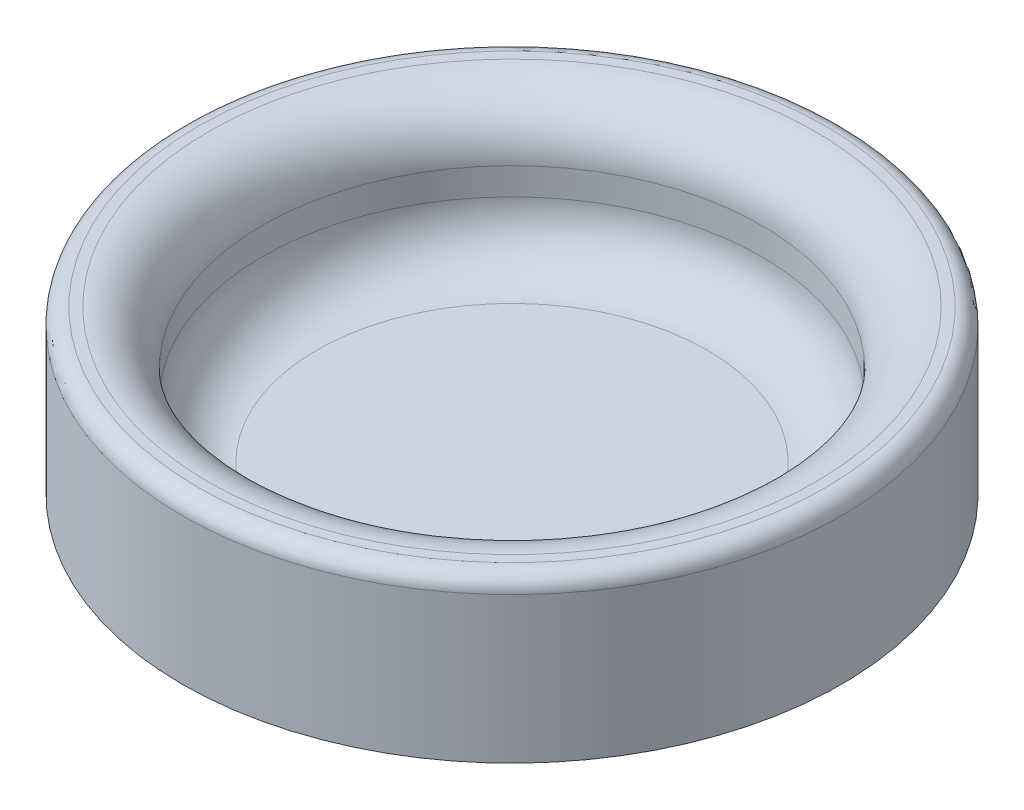
from build123d import *

# Parameters (mm, degrees)
SKETCH1_R           = 60.957989534
BOSS_EXTRUDE1_DEPTH = 5
SKETCH1_4_R         = 60.957989534
SKETCH1_4_R_2       = 46.132101341
BOSS_EXTRUDE2_DEPTH = 30
FILLET2_R           = 10
FILLET3_R           = 10
FILLET5_R           = 3


with BuildPart() as part:
    # Sketch1 → Boss-Extrude1 (new body)
    with BuildSketch(Plane(origin=(0, 0, 0), x_dir=(1, 0, 0), z_dir=(0, 1, 0))):
        with Locations((-18.5585839, 19.037515097)):
            Circle(SKETCH1_R)
    extrude(amount=BOSS_EXTRUDE1_DEPTH)

    # Sketch1_4 → Boss-Extrude2 (add)
    with BuildSketch(Plane(origin=(0, 0, 0), x_dir=(1, 0, 0), z_dir=(0, 1, 0))):
        with Locations((-18.5585839, 19.037515097)):
            Circle(SKETCH1_4_R)
        with Locations((-18.5585839, 19.037515097)):
            Circle(SKETCH1_4_R_2, mode=Mode.SUBTRACT)
    extrude(amount=BOSS_EXTRUDE2_DEPTH)

    # Fillet2
    fillet2_edges = [part.edges().sort_by_distance(p)[0] for p in [
        (-64.69068524, 5, -19.037515097),
    ]]
    fillet(fillet2_edges, radius=FILLET2_R)

    # Fillet3
    fillet3_edges = [part.edges().sort_by_distance(p)[0] for p in [
        (-64.69068524, 30, -19.037515097),
    ]]
    fillet(fillet3_edges, radius=FILLET3_R)

    # Fillet5
    fillet5_edges = [part.edges().sort_by_distance(p)[0] for p in [
        (-79.516573434, 30, -19.037515097),
    ]]
    fillet(fillet5_edges, radius=FILLET5_R)


solid = part.part
